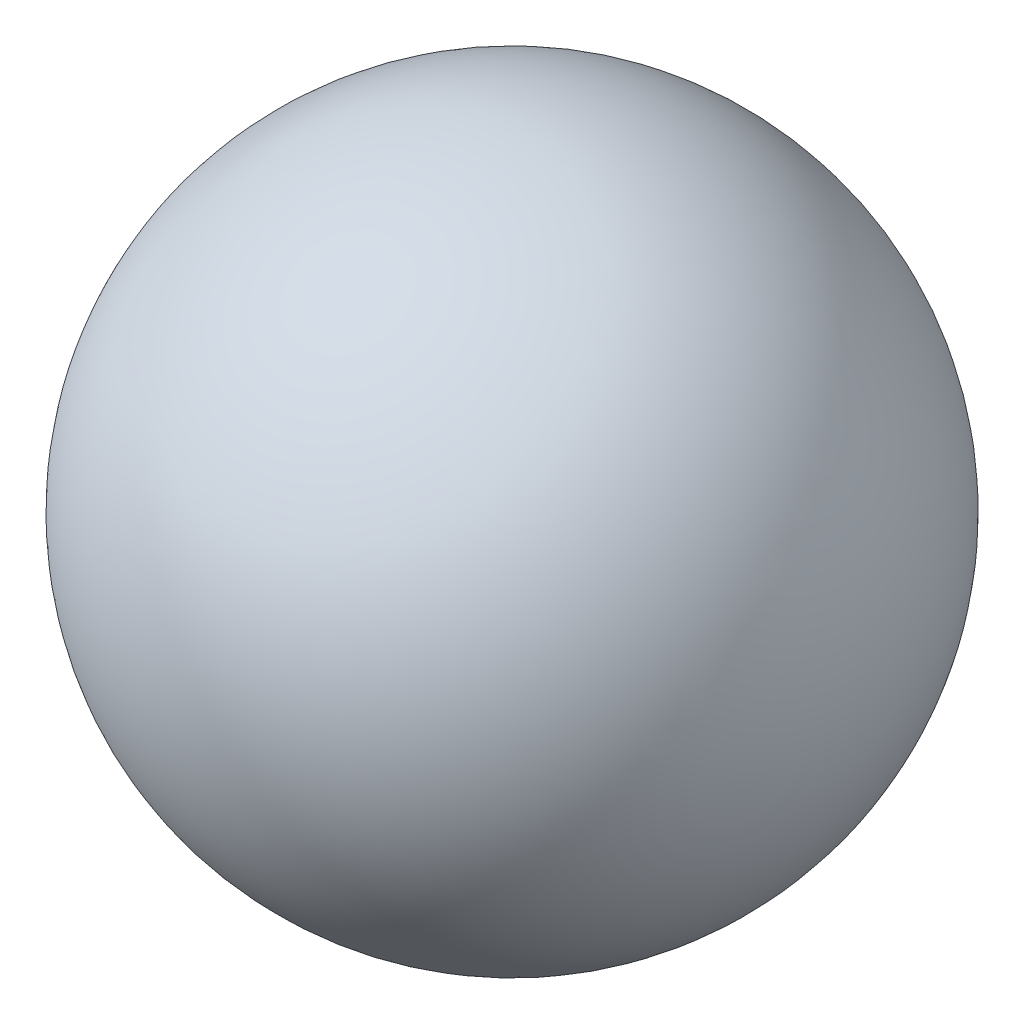
from build123d import *


with BuildPart() as part:
    # Sketch2 → Revolve1 (revolve)
    with BuildSketch(Plane.XY):
        with BuildLine():
            Line((1809.06577988, 0), (-1809.06577988, 0))
            ThreePointArc((-1809.06577988, 0), (0, 1809.06577988), (1809.06577988, 0))
        make_face()
    revolve(axis=Axis((1809.06577988, 0, 0), (-1, 0, 0)))


solid = part.part
